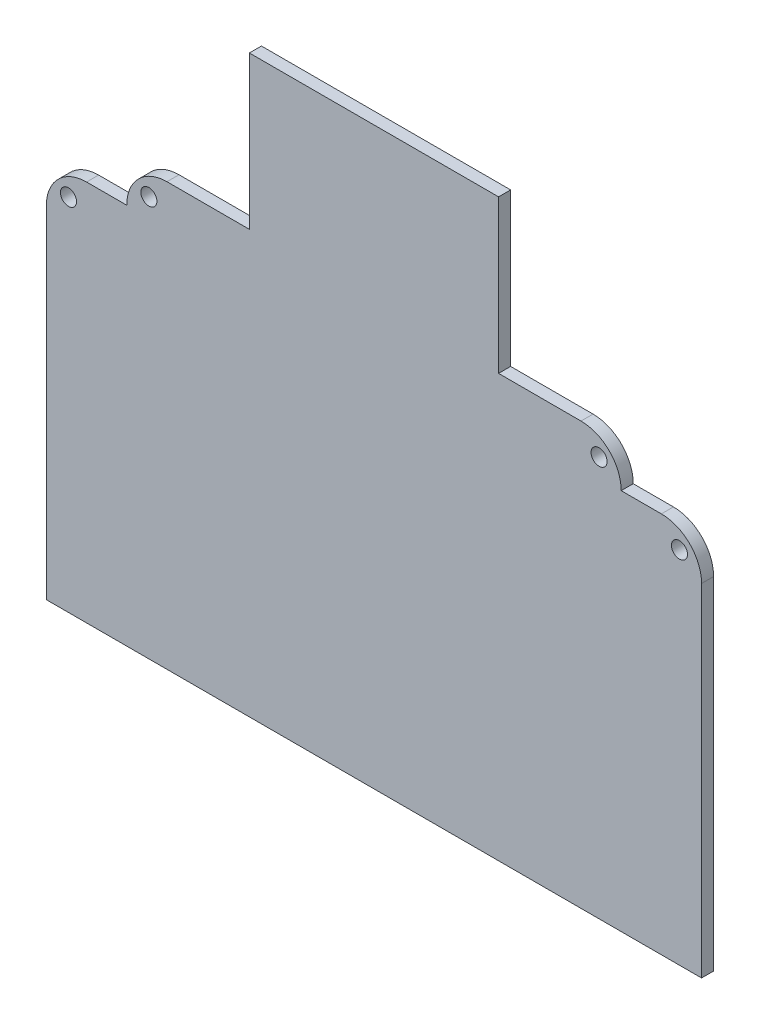
from build123d import *

# Parameters (mm, degrees)
BOSS_EXTRU_1_DEPTH      = 3
ESQUISSE4_R             = 2
ENL_V_MAT_EXTRU_1_DEPTH = 10
BOSS_EXTRU_2_DEPTH      = 3
ESQUISSE6_W             = 163
ESQUISSE6_H             = 80
BOSS_EXTRU_3_DEPTH      = 3


with BuildPart() as part:
    # Esquisse2 → Boss.-Extru.1 (new body)
    with BuildSketch(Plane.XY):
        with BuildLine():
            Line((-57.997011135, -5.009122385), (105.002988865, -5.009122385))
            Line((105.002988865, -5.009122385), (105.002988865, -0.009122385))
            ThreePointArc((105.002988865, -0.009122385), (102.074056676, 7.061945427), (95.002988865, 9.990877615))
            Line((95.002988865, 9.990877615), (85.002988865, 9.990877615))
            Line((85.002988865, 9.990877615), (85.002988865, 9.996878601))
            ThreePointArc((85.002988865, 9.996878601), (82.076178664, 17.065823789), (75.008991651, 19.9968768))
            Line((75.008991651, 19.9968768), (-27.995184752, 20.058708021))
            Line((-27.995184752, 20.058708021), (-27.997011135, 20.058708021))
            ThreePointArc((-27.997011135, 20.058708021), (-35.068078947, 17.129775833), (-37.997011135, 10.058708021))
            Line((-37.997011135, 10.058708021), (-37.997011135, 9.990877615))
            Line((-37.997011135, 9.990877615), (-47.997011135, 9.990877615))
            ThreePointArc((-47.997011135, 9.990877615), (-55.068078947, 7.061945427), (-57.997011135, -0.009122385))
            Line((-57.997011135, -0.009122385), (-57.997011135, -5.009122385))
        make_face()
    extrude(amount=BOSS_EXTRU_1_DEPTH)

    # Esquisse4 → Enlèv. mat.-Extru.1 (cut)
    with BuildSketch(Plane.XY.offset(3)):
        with Locations((-32.497011135, 14.558708021)):
            Circle(ESQUISSE4_R)
        with Locations((79.502988865, 14.494178158)):
            Circle(ESQUISSE4_R)
        with Locations((99.502988865, 4.490877615)):
            Circle(ESQUISSE4_R)
        with Locations((-52.497011135, 4.490877615)):
            Circle(ESQUISSE4_R)
    extrude(amount=-ENL_V_MAT_EXTRU_1_DEPTH, mode=Mode.SUBTRACT)

    # Esquisse5 → Boss.-Extru.2 (add)
    with BuildSketch(Plane.XY.offset(3)):
        Polygon((-7.497011135, 20.046403402), (-7.497011135, 58.046403402), (54.502988865, 58.046403402), (54.502988865, 20.009186118), align=None)
    extrude(amount=-BOSS_EXTRU_2_DEPTH)

    # Esquisse6 → Boss.-Extru.3 (add)
    with BuildSketch(Plane.XY.offset(3)):
        with Locations((23.502988865, -45.009122385)):
            Rectangle(ESQUISSE6_W, ESQUISSE6_H)
    extrude(amount=-BOSS_EXTRU_3_DEPTH)


solid = part.part
